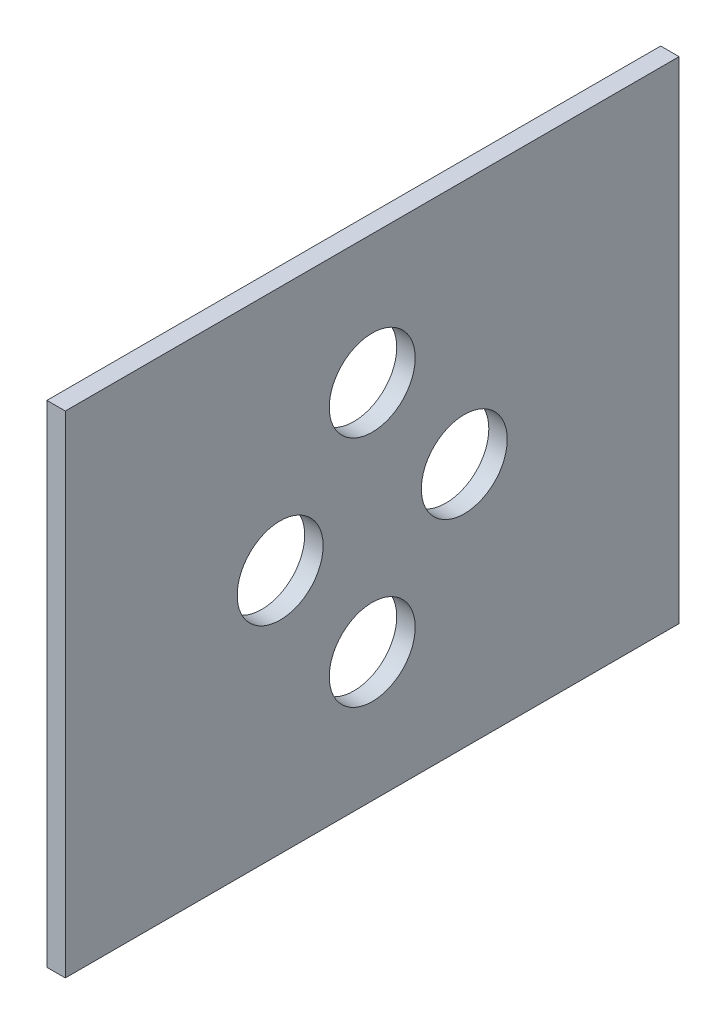
from build123d import *

# Parameters (mm, degrees)
SKETCH1_W           = 50
SKETCH1_H           = 40
BOSS_EXTRUDE1_DEPTH = 1.5
SKETCH2_R           = 3.5
CUT_EXTRUDE1_DEPTH  = 11.5


with BuildPart() as part:
    # Sketch1 → Boss-Extrude1 (new body)
    with BuildSketch(Plane(origin=(0, 0, 0), x_dir=(0, 0, -1), z_dir=(1, 0, 0))):
        Rectangle(SKETCH1_W, SKETCH1_H)
    extrude(amount=BOSS_EXTRUDE1_DEPTH)

    # Sketch2 → Cut-Extrude1 (cut)
    with BuildSketch(Plane(origin=(1.5, 0, 0), x_dir=(0, 0, -1), z_dir=(1, 0, 0))):
        with Locations((0, 9.5)):
            Circle(SKETCH2_R)
        with Locations((0, -9.5)):
            Circle(SKETCH2_R)
        with Locations((7.5, 0)):
            Circle(SKETCH2_R)
        with Locations((-7.5, 0)):
            Circle(SKETCH2_R)
    extrude(amount=-CUT_EXTRUDE1_DEPTH, mode=Mode.SUBTRACT)


solid = part.part
